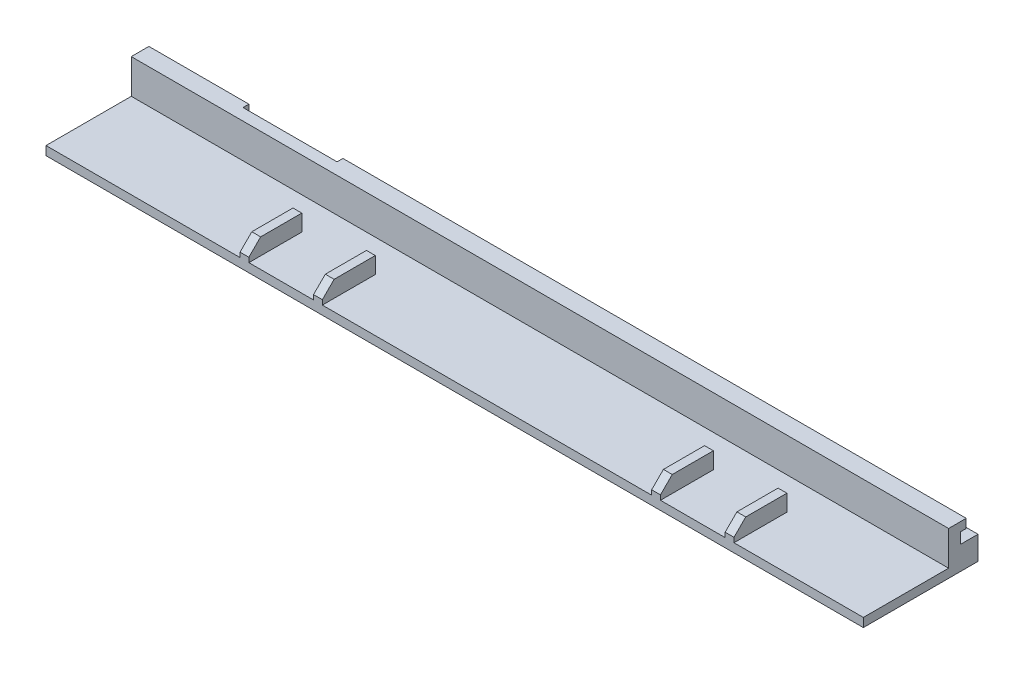
from build123d import *

# Parameters (mm, degrees)
BOSS_EXTRUDE1_DEPTH = 150
SKETCH2_W           = 1.5
SKETCH2_H           = 9
BOSS_EXTRUDE2_DEPTH = 2.8
SKETCH4_W           = 16
SKETCH4_H           = 3
SKETCH4_W_2         = 11
SKETCH4_H_2         = 19.5
CUT_EXTRUDE2_DEPTH  = 22
CHAMFER1_SIZE       = 2


with BuildPart() as part:
    # Sketch1 → Boss-Extrude1 (new body)
    with BuildSketch(Plane(origin=(0, 0, 0), x_dir=(0, 0, -1), z_dir=(1, 0, 0))):
        Polygon((0, 0), (-16.5, 0), (-16.5, 1.5), (-2, 1.5), (-2, 4), (-2, 7.35), (1, 7.35), (1, 5.85), (0, 5.85), (0, 4), (3, 4), (3, 0), align=None)
    extrude(amount=BOSS_EXTRUDE1_DEPTH)

    # Sketch2 → Boss-Extrude2 (add)
    with BuildSketch(Plane(origin=(0, 1.5, 0), x_dir=(1, 0, 0), z_dir=(0, 1, 0))):
        with Locations((33.75, -12)):
            Rectangle(SKETCH2_W, SKETCH2_H)
        with Locations((46.25, -12)):
            Rectangle(SKETCH2_W, SKETCH2_H)
        with Locations((103.75, -12)):
            Rectangle(SKETCH2_W, SKETCH2_H)
        with Locations((116.25, -12)):
            Rectangle(SKETCH2_W, SKETCH2_H)
    extrude(amount=BOSS_EXTRUDE2_DEPTH)

    # Sketch4 → Cut-Extrude2 (cut)
    with BuildSketch(Plane(origin=(0, 7.35, 0), x_dir=(1, 0, 0), z_dir=(0, 1, 0))):
        with Locations((25, 1.5)):
            Rectangle(SKETCH4_W, SKETCH4_H)
        with Locations((144.5, -6.75)):
            Rectangle(SKETCH4_W_2, SKETCH4_H_2)
    extrude(amount=-CUT_EXTRUDE2_DEPTH, mode=Mode.SUBTRACT)

    # Chamfer1
    chamfer1_edges = [part.edges().sort_by_distance(p)[0] for p in [
        (33.75, 4.3, 16.5),
        (46.25, 4.3, 16.5),
        (103.75, 4.3, 16.5),
        (116.25, 4.3, 16.5),
    ]]
    chamfer(chamfer1_edges, length=CHAMFER1_SIZE)


solid = part.part
